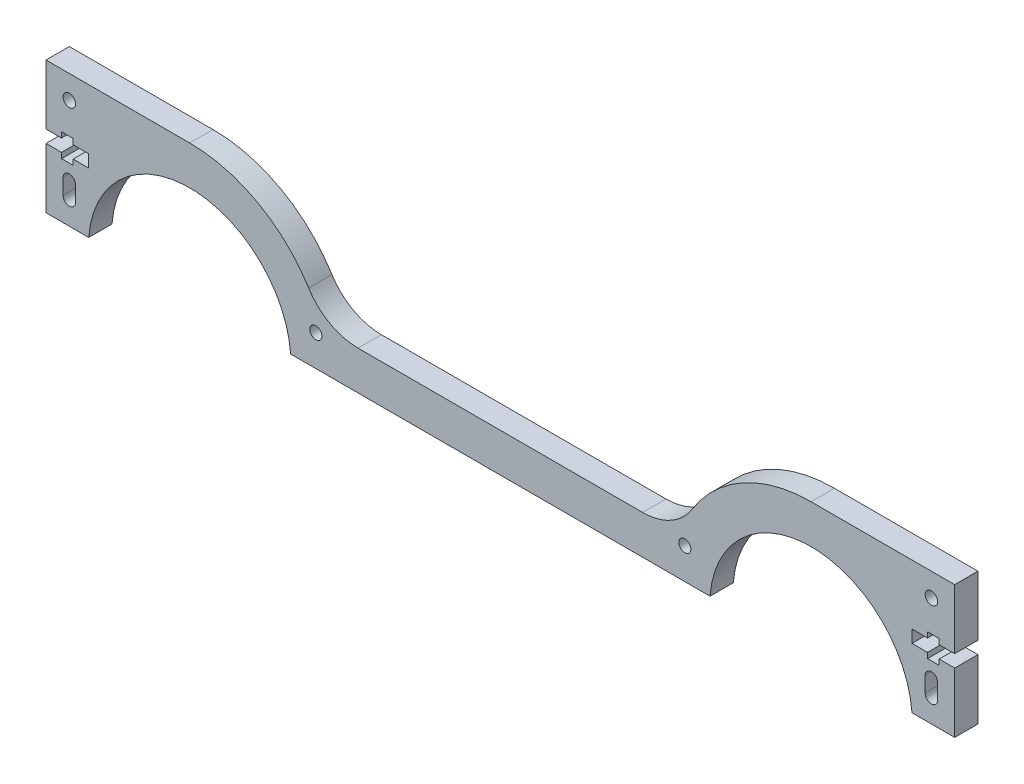
from build123d import *

# Parameters (mm, degrees)
ESBO_O1_R                = 1.55
RESSALTO_EXTRUS_O1_DEPTH = 6
ESBO_O2_R                = 1.6
CORTE_EXTRUS_O1_DEPTH    = 10


with BuildPart() as part:
    # Esboço1 → Ressalto-extrusão1 (new body)
    with BuildSketch(Plane.XY):
        with BuildLine():
            Line((-117, -30), (-106, -30))
            ThreePointArc((-106, -30), (-80, -5.923190379), (-54, -30))
            Line((-54, -30), (0, -30))
            Line((0, -30), (54, -30))
            ThreePointArc((54, -30), (80, -5.923190379), (106, -30))
            Line((106, -30), (117, -30))
            Line((117, -30), (117, -14.523190379))
            Line((117, -14.523190379), (113, -14.523190379))
            Line((113, -14.523190379), (113, -15.923190379))
            Line((113, -15.923190379), (110, -15.923190379))
            Line((110, -15.923190379), (110, -14.523190379))
            Line((110, -14.523190379), (106, -14.523190379))
            Line((106, -14.523190379), (106, -11.323190379))
            Line((106, -11.323190379), (110, -11.323190379))
            Line((110, -11.323190379), (110, -9.923190379))
            Line((110, -9.923190379), (113, -9.923190379))
            Line((113, -9.923190379), (113, -11.323190379))
            Line((113, -11.323190379), (117, -11.323190379))
            Line((117, -11.323190379), (117, 4.076809621))
            Line((117, 4.076809621), (80, 4.076809621))
            ThreePointArc((80, 4.076809621), (62.485380172, -0.45995744), (49.375792338, -12.929234481))
            ThreePointArc((49.375792338, -12.929234481), (43.925093688, -18.113704991), (36.642872777, -20))
            Line((36.642872777, -20), (-36.642872777, -20))
            ThreePointArc((-36.642872777, -20), (-43.925093688, -18.113704991), (-49.375792338, -12.929234481))
            ThreePointArc((-49.375792338, -12.929234481), (-62.485380172, -0.45995744), (-80, 4.076809621))
            Line((-80, 4.076809621), (-117, 4.076809621))
            Line((-117, 4.076809621), (-117, -11.323190379))
            Line((-117, -11.323190379), (-113, -11.323190379))
            Line((-113, -11.323190379), (-113, -9.923190379))
            Line((-113, -9.923190379), (-110, -9.923190379))
            Line((-110, -9.923190379), (-110, -11.323190379))
            Line((-110, -11.323190379), (-106, -11.323190379))
            Line((-106, -11.323190379), (-106, -14.523190379))
            Line((-106, -14.523190379), (-110, -14.523190379))
            Line((-110, -14.523190379), (-110, -15.923190379))
            Line((-110, -15.923190379), (-113, -15.923190379))
            Line((-113, -15.923190379), (-113, -14.523190379))
            Line((-113, -14.523190379), (-117, -14.523190379))
            Line((-117, -14.523190379), (-117, -30))
        make_face()
        with Locations((-47.5, -22)):
            Circle(ESBO_O1_R, mode=Mode.SUBTRACT)
        with Locations((47.5, -22)):
            Circle(ESBO_O1_R, mode=Mode.SUBTRACT)
    extrude(amount=RESSALTO_EXTRUS_O1_DEPTH)

    # Esboço2 → Corte-extrusão1 (cut)
    with BuildSketch(Plane.XY.offset(6)):
        with Locations((-111, -1.923190379)):
            Circle(ESBO_O2_R)
        with Locations((111, -1.923190379)):
            Circle(ESBO_O2_R)
        with BuildLine():
            Line((-109.4, -19.923190379), (-109.4, -23.923190379))
            ThreePointArc((-109.4, -23.923190379), (-111, -25.523190379), (-112.6, -23.923190379))
            Line((-112.6, -23.923190379), (-112.6, -19.923190379))
            ThreePointArc((-112.6, -19.923190379), (-111, -18.323190379), (-109.4, -19.923190379))
        make_face()
        with BuildLine():
            Line((109.4, -19.923190379), (109.4, -23.923190379))
            ThreePointArc((109.4, -23.923190379), (111, -25.523190379), (112.6, -23.923190379))
            Line((112.6, -23.923190379), (112.6, -19.923190379))
            ThreePointArc((112.6, -19.923190379), (111, -18.323190379), (109.4, -19.923190379))
        make_face()
    extrude(amount=-CORTE_EXTRUS_O1_DEPTH, mode=Mode.SUBTRACT)


solid = part.part
